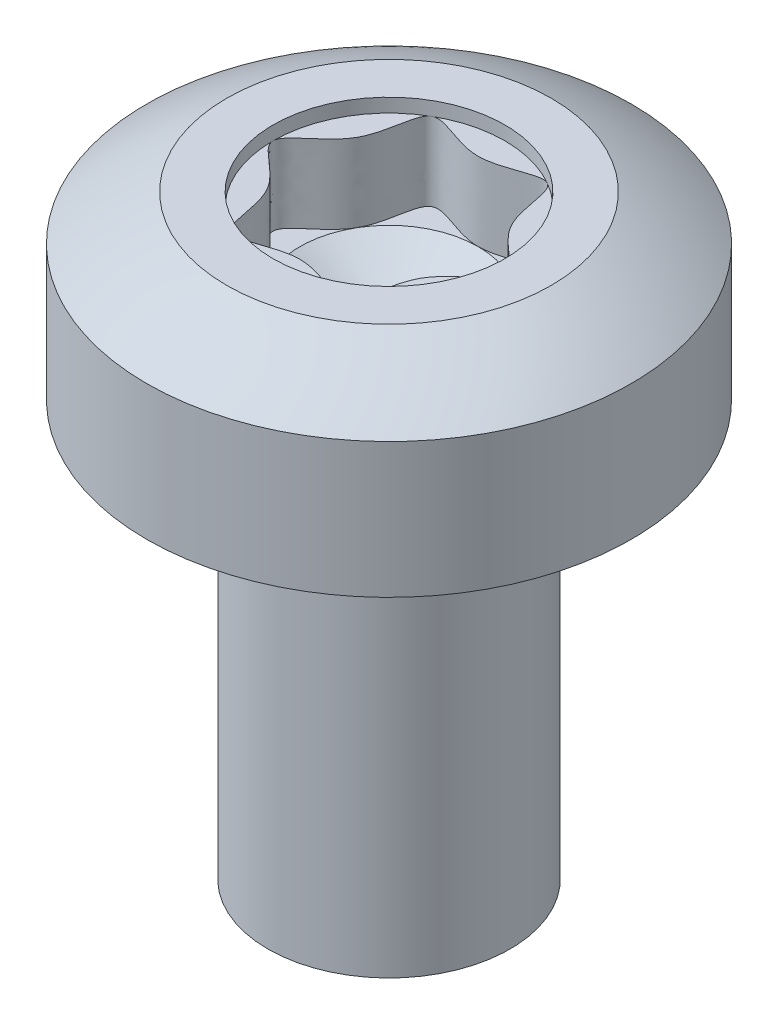
from build123d import *

# Parameters (mm, degrees)
RECESS_CUT_EXTRUDE1_DEPTH = 1.33
SKETCH7_R                 = 1.675
RECESS_CUT_EXTRUDE2_DEPTH = 0.1995


with BuildPart() as part:
    # Sketch1 → BODY (revolve)
    with BuildSketch(Plane.XY):
        Polygon((0, 0), (1.75, 0), (1.75, 6), (3.5, 6), (3.5, 8.6), (0, 8.6), align=None)
    revolve(axis=Axis((0, 0, 0), (0, 1, 0)))

    # Sketch2 → HEAD-CUT (revolve, cut)
    with BuildSketch(Plane.XY):
        with BuildLine():
            ThreePointArc((6, 3.076602828), (4.242640687, 7.319243515), (0, 9.076602828))
            Line((0, 9.076602828), (0, 9.558764398))
            Line((0, 9.558764398), (6, 9.558764398))
            Line((6, 9.558764398), (6, 3.076602828))
        make_face()
    revolve(axis=Axis((0, 0, 0), (0, 1, 0)), mode=Mode.SUBTRACT)

    # Sketch4 → GAP (revolve, cut)
    with BuildSketch(Plane.XY):
        with BuildLine():
            Line((-1.75, 4.8), (-1.684212961, 5.9))
            ThreePointArc((-1.684212961, 5.9), (-1.700491957, 5.960930203), (-1.75, 6))
            Line((-1.75, 6), (-1.75, 4.8))
        make_face()
    revolve(axis=Axis((0, 0, 0), (0, 1, 0)), mode=Mode.SUBTRACT)

    # Sketch5 → Recess-Cut-Extrude1 (cut)
    with BuildSketch(Plane(origin=(0, 8.6, 0), x_dir=(-1, 0, 0), z_dir=(0, 1, 0))):
        with BuildLine():
            add(Edge.make_bspline(
                [(0.8375, -1.450592551), (0.987566284, -1.363951742), (0.900397706, -0.519844858), (1.675, -0.173281619), (1.675, 0)],
                knots=[0.583333333, 0.583333333, 0.583333333, 0.583333333, 0.666666667, 0.75, 0.75, 0.75, 0.75], degree=3))
            add(Edge.make_bspline(
                [(1.675, 0), (1.675, 0.173281619), (0.900397706, 0.519844858), (0.987566284, 1.363951742), (0.8375, 1.450592551)],
                knots=[0.75, 0.75, 0.75, 0.75, 0.833333333, 0.916666667, 0.916666667, 0.916666667, 0.916666667], degree=3))
            add(Edge.make_bspline(
                [(0.8375, 1.450592551), (0.687433716, 1.537233361), (0.343716858, 1.288461538), (0, 1.288461538)],
                knots=[0.916666667, 0.916666667, 0.916666667, 0.916666667, 1, 1, 1, 1], degree=3))
            add(Edge.make_bspline(
                [(0, 1.288461538), (-0.343716858, 1.288461538), (-0.687433716, 1.537233361), (-0.8375, 1.450592551)],
                knots=[0, 0, 0, 0, 0.083333333, 0.083333333, 0.083333333, 0.083333333], degree=3))
            add(Edge.make_bspline(
                [(-0.8375, 1.450592551), (-0.987566284, 1.363951742), (-0.900397706, 0.519844858), (-1.675, 0.173281619), (-1.675, 0)],
                knots=[0.083333333, 0.083333333, 0.083333333, 0.083333333, 0.166666667, 0.25, 0.25, 0.25, 0.25], degree=3))
            add(Edge.make_bspline(
                [(-1.675, 0), (-1.675, -0.173281619), (-0.900397706, -0.519844858), (-0.987566284, -1.363951742), (-0.8375, -1.450592551)],
                knots=[0.25, 0.25, 0.25, 0.25, 0.333333333, 0.416666667, 0.416666667, 0.416666667, 0.416666667], degree=3))
            add(Edge.make_bspline(
                [(-0.8375, -1.450592551), (-0.687433716, -1.537233361), (0, -1.039689716), (0.687433716, -1.537233361), (0.8375, -1.450592551)],
                knots=[0.416666667, 0.416666667, 0.416666667, 0.416666667, 0.5, 0.583333333, 0.583333333, 0.583333333, 0.583333333], degree=3))
        make_face()
    extrude(amount=-RECESS_CUT_EXTRUDE1_DEPTH, mode=Mode.SUBTRACT)

    # Sketch3 → DRILL-CUT (revolve, cut)
    with BuildSketch(Plane.XY):
        Polygon((0, 6.526106384), (1.288461538, 7.27), (0, 7.27), align=None)
    revolve(axis=Axis((0, 0, 0), (0, 1, 0)), mode=Mode.SUBTRACT)

    # Sketch7 → Recess-Cut-Extrude2 (cut)
    with BuildSketch(Plane(origin=(0, 8.6, 0), x_dir=(-1, 0, 0), z_dir=(0, 1, 0))):
        Circle(SKETCH7_R)
    extrude(amount=-RECESS_CUT_EXTRUDE2_DEPTH, mode=Mode.SUBTRACT)


solid = part.part
